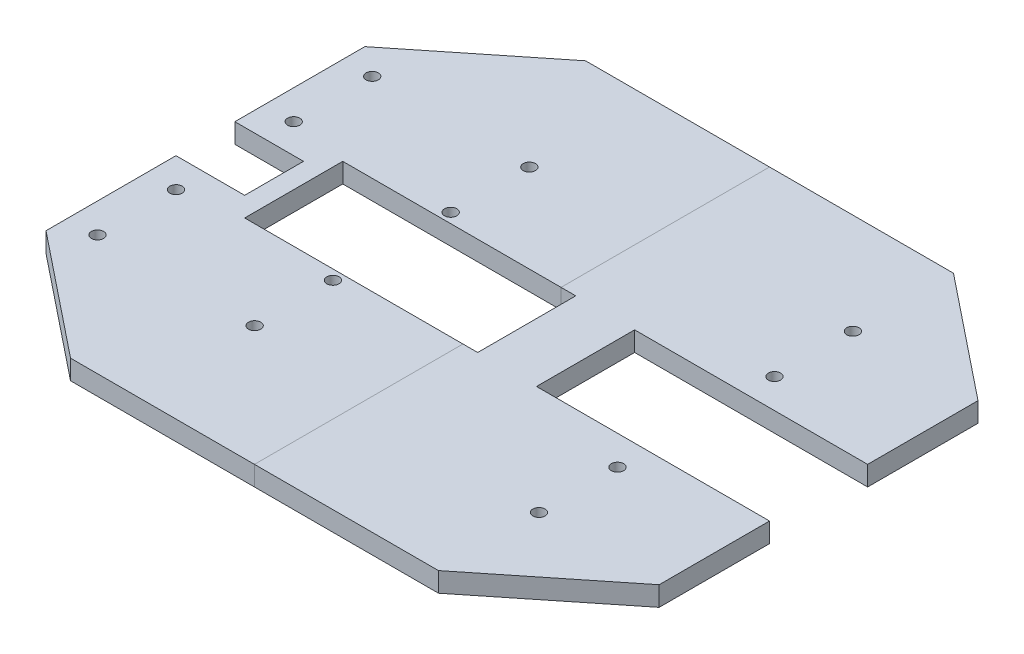
from build123d import *

# Parameters (mm, degrees)
SKETCH1_W           = 250
SKETCH1_H           = 130
BOSS_EXTRUDE1_DEPTH = 8
SKETCH2_W           = 95
SKETCH2_H           = 40
CUT_EXTRUDE1_DEPTH  = 8
SKETCH3_W           = 28
SKETCH3_H           = 24
CUT_EXTRUDE2_DEPTH  = 8
SKETCH4_W           = 95
SKETCH4_H           = 40
CUT_EXTRUDE3_DEPTH  = 8
BOSS_EXTRUDE2_DEPTH = 8
SKETCH6_R           = 2.5
CUT_EXTRUDE4_DEPTH  = 8
SKETCH7_R           = 2.5
CUT_EXTRUDE5_DEPTH  = 8
SKETCH8_R           = 2.5
CUT_EXTRUDE6_DEPTH  = 8


with BuildPart() as part:
    # Sketch1 → Boss-Extrude1 (new body)
    with BuildSketch(Plane(origin=(0, 0, 0), x_dir=(1, 0, 0), z_dir=(0, 1, 0))):
        with Locations((17.879353234, 4.987562189)):
            Rectangle(SKETCH1_W, SKETCH1_H)
    extrude(amount=BOSS_EXTRUDE1_DEPTH)

    # Sketch2 → Cut-Extrude1 (cut)
    with BuildSketch(Plane(origin=(0, 8, 0), x_dir=(1, 0, 0), z_dir=(0, 1, 0))):
        with Locations((95.379353234, 4.987562189)):
            Rectangle(SKETCH2_W, SKETCH2_H)
    extrude(amount=-CUT_EXTRUDE1_DEPTH, mode=Mode.SUBTRACT)

    # Sketch3 → Cut-Extrude2 (cut)
    with BuildSketch(Plane(origin=(0, 8, 0), x_dir=(1, 0, 0), z_dir=(0, 1, 0))):
        with Locations((-93.120646766, 4.987562189)):
            Rectangle(SKETCH3_W, SKETCH3_H)
    extrude(amount=-CUT_EXTRUDE2_DEPTH, mode=Mode.SUBTRACT)

    # Sketch4 → Cut-Extrude3 (cut)
    with BuildSketch(Plane(origin=(0, 8, 0), x_dir=(1, 0, 0), z_dir=(0, 1, 0))):
        with Locations((-23.620646766, 4.987562189)):
            Rectangle(SKETCH4_W, SKETCH4_H)
    extrude(amount=-CUT_EXTRUDE3_DEPTH, mode=Mode.SUBTRACT)

    # Sketch5 → Boss-Extrude2 (add)
    with BuildSketch(Plane.XZ):
        Polygon((-107.120646766, 60.012437811), (-57.120646766, 100.012437811), (92.879353234, 100.012437811), (142.879353234, 60.012437811), align=None)
        Polygon((-107.120646766, -69.987562189), (-57.120646766, -109.987562189), (92.879353234, -109.987562189), (142.879353234, -69.987562189), align=None)
    extrude(amount=-BOSS_EXTRUDE2_DEPTH)

    # Sketch6 → Cut-Extrude4 (cut)
    with BuildSketch(Plane(origin=(0, 8, 0), x_dir=(1, 0, 0), z_dir=(0, 1, 0))):
        with Locations((92.879353234, -27.012437811)):
            Circle(SKETCH6_R)
        with Locations((92.879353234, -59.012437811)):
            Circle(SKETCH6_R)
    cut_extrude4 = extrude(amount=-CUT_EXTRUDE4_DEPTH, mode=Mode.SUBTRACT)

    # Sketch7 → Cut-Extrude5 (cut)
    with BuildSketch(Plane(origin=(0, 8, 0), x_dir=(1, 0, 0), z_dir=(0, 1, 0))):
        with Locations((-95.120646766, -19.012437811)):
            Circle(SKETCH7_R)
        with Locations((-95.120646766, -51.012437811)):
            Circle(SKETCH7_R)
    cut_extrude5 = extrude(amount=-CUT_EXTRUDE5_DEPTH, mode=Mode.SUBTRACT)

    # Mirror1: Cut-Extrude4, Cut-Extrude5 across plane
    add(cut_extrude4.mirror(Plane.XY.offset(-4.987562189)), mode=Mode.SUBTRACT)
    add(cut_extrude5.mirror(Plane.XY.offset(-4.987562189)), mode=Mode.SUBTRACT)

    # Sketch8 → Cut-Extrude6 (cut)
    with BuildSketch(Plane(origin=(0, 8, 0), x_dir=(1, 0, 0), z_dir=(0, 1, 0))):
        with Locations((-31.120646766, -19.012437811)):
            Circle(SKETCH8_R)
        with Locations((-31.051544466, -51.012437811)):
            Circle(SKETCH8_R)
    cut_extrude6 = extrude(amount=-CUT_EXTRUDE6_DEPTH, mode=Mode.SUBTRACT)

    # Mirror2: Cut-Extrude6 across plane
    add(cut_extrude6.mirror(Plane.XY.offset(-4.987562189)), mode=Mode.SUBTRACT)


with BuildPart() as body_2:
    # Split1: the piece on the far side of the plane
    add(part.part)
    split(bisect_by=Plane(origin=(17.879353234, 0, 0), x_dir=(0, 0, -1), z_dir=(-1, 0, 0)), keep=Keep.BOTTOM)


with BuildPart() as part_1:
    add(part.part)

    # Split1
    split(bisect_by=Plane(origin=(17.879353234, 0, 0), x_dir=(0, 0, -1), z_dir=(-1, 0, 0)), keep=Keep.TOP)


solid = Compound([body_2.part, part_1.part])
